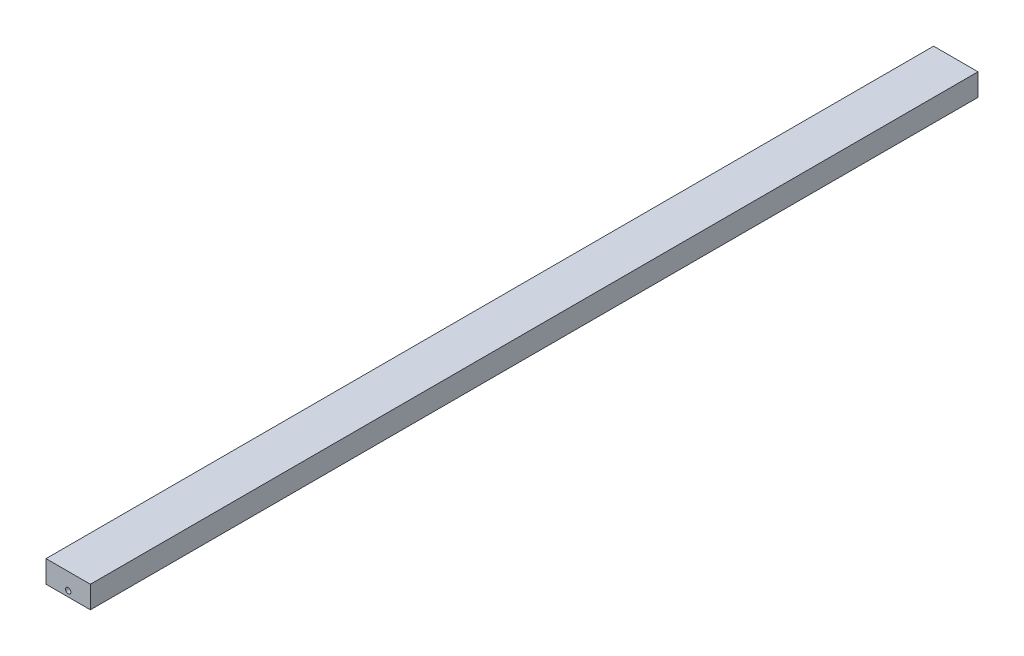
from build123d import *

# Parameters (mm, degrees)
SKIZZE1_W                       = 10
SKIZZE1_H                       = 5
AUFSATZ_LINEAR_AUSTRAGEN1_DEPTH = 200
SKIZZE2_R                       = 0.6
SCHNITT_LINEAR_AUSTRAGEN1_DEPTH = 201


with BuildPart() as part:
    # Skizze1 → Aufsatz-Linear austragen1 (new body)
    with BuildSketch(Plane.XY):
        Rectangle(SKIZZE1_W, SKIZZE1_H)
    extrude(amount=AUFSATZ_LINEAR_AUSTRAGEN1_DEPTH)

    # Skizze2 → Schnitt-Linear austragen1 (cut, through all)
    with BuildSketch(Plane.XY):
        with Locations((0, -1.25)):
            Circle(SKIZZE2_R)
    extrude(amount=SCHNITT_LINEAR_AUSTRAGEN1_DEPTH, mode=Mode.SUBTRACT)


solid = part.part
